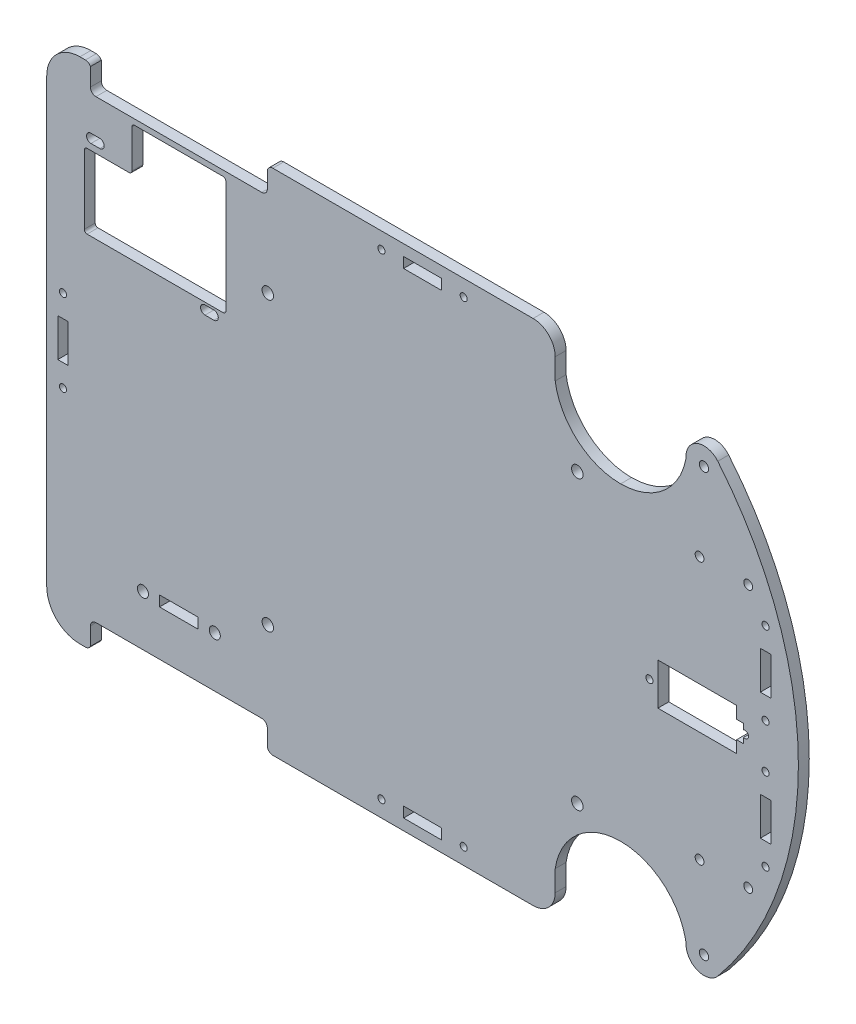
from build123d import *

# Parameters (mm, degrees)
CROQUIS1_W                  = 215.9
CROQUIS1_H                  = 146.05
SALIENTE_EXTRUIR1_DEPTH     = 3.1242
CROQUIS2_R                  = 1.3335
CORTAR_EXTRUIR1_DEPTH       = 131.36722652
CROQUIS9_R                  = 1.27
CORTAR_EXTRUIR6_DEPTH       = 131.36722652
CORTAR_EXTRUIR2_DEPTH       = 131.36722652
DIFERENCIAL_TRASERO_DEPTH   = 131.36722652
ENTRADA_TRANSMISION_DEPTH   = 131.36722652
CROQUIS10_R                 = 1.016
SERVO_DEPTH                 = 131.36722652
CROQUIS12_R                 = 1.651
SOPORTES_BS_DEPTH           = 131.36722652
CROQUIS7_W                  = 11.1125
CROQUIS7_H                  = 2.9972
CROQUIS7_R                  = 1.5875
SOPORTE_EJE_DEPTH           = 131.36722652
CROQUIS13_R                 = 1.016
CROQUIS13_W                 = 10.922
CROQUIS13_H                 = 2.9972
CROQUIS13_W_2               = 2.9972
CROQUIS13_H_2               = 10.922
SENSORES_DE_PRESENCIA_DEPTH = 131.36722652


with BuildPart() as part:
    # Croquis1 → Saliente-Extruir1 (new body)
    with BuildSketch(Plane.XY):
        Rectangle(CROQUIS1_W, CROQUIS1_H)
    extrude(amount=SALIENTE_EXTRUIR1_DEPTH)

    # Croquis2 → Cortar-Extruir1 (cut, through all)
    with BuildSketch(Plane.XY.offset(3.1242)):
        with Locations((80.8339125, 60.7314)):
            Circle(CROQUIS2_R)
        with Locations((80.8339125, -60.7314)):
            Circle(CROQUIS2_R)
    extrude(amount=-CORTAR_EXTRUIR1_DEPTH, mode=Mode.SUBTRACT)

    # Croquis9 → Cortar-Extruir6 (cut, through all)
    with BuildSketch(Plane.XY.offset(3.1242)):
        with Locations((93.5339125, 37.6809)):
            Circle(CROQUIS9_R)
        with Locations((93.5339125, -37.6809)):
            Circle(CROQUIS9_R)
        with Locations((79.5639125, 37.6809)):
            Circle(CROQUIS9_R)
        with Locations((79.5639125, -37.6809)):
            Circle(CROQUIS9_R)
    extrude(amount=-CORTAR_EXTRUIR6_DEPTH, mode=Mode.SUBTRACT)

    # Croquis3 → Cortar-Extruir2 (cut, through all)
    with BuildSketch(Plane.XY.offset(3.1242)):
        with BuildLine():
            ThreePointArc((31.75, 73.025), (36.240128061, 71.165128061), (38.1, 66.675))
            Line((38.1, 66.675), (38.1, 60.648925294))
            ThreePointArc((38.1, 60.648925294), (44.483976367, 49.058906773), (56.88726875, 44.45))
            ThreePointArc((56.88726875, 44.45), (68.952768587, 48.752886462), (75.572740263, 59.719521917))
            ThreePointArc((75.572740263, 59.719521917), (75.649024122, 60.222907145), (75.6745375, 60.7314))
            ThreePointArc((75.6745375, 60.7314), (79.079726884, 65.583408163), (84.800442563, 64.030762007))
            ThreePointArc((84.800442563, 64.030762007), (101.984927744, 34.043503392), (107.95, 0))
            Line((107.95, 0), (107.95, 73.025))
            Line((107.95, 73.025), (31.75, 73.025))
        make_face()
        with BuildLine():
            Line((107.95, -73.025), (107.95, 0))
            ThreePointArc((107.95, 0), (101.984927744, -34.043503392), (84.800442563, -64.030762007))
            ThreePointArc((84.800442563, -64.030762007), (79.079726884, -65.583408163), (75.6745375, -60.7314))
            ThreePointArc((75.6745375, -60.7314), (75.649024122, -60.222907145), (75.572740263, -59.719521917))
            ThreePointArc((75.572740263, -59.719521917), (68.952768587, -48.752886462), (56.88726875, -44.45))
            ThreePointArc((56.88726875, -44.45), (44.483976367, -49.058906773), (38.1, -60.648925294))
            Line((38.1, -60.648925294), (38.1, -66.675))
            ThreePointArc((38.1, -66.675), (36.240128061, -71.165128061), (31.75, -73.025))
            Line((31.75, -73.025), (107.95, -73.025))
        make_face()
        with BuildLine():
            ThreePointArc((-107.95, 63.5), (-105.160192091, 70.235192091), (-98.425, 73.025))
            Line((-98.425, 73.025), (-107.95, 73.025))
            Line((-107.95, 73.025), (-107.95, 63.5))
        make_face()
        with BuildLine():
            Line((-107.95, -73.025), (-98.425, -73.025))
            ThreePointArc((-98.425, -73.025), (-105.160192091, -70.235192091), (-107.95, -63.5))
            Line((-107.95, -63.5), (-107.95, -73.025))
        make_face()
    extrude(amount=-CORTAR_EXTRUIR2_DEPTH, mode=Mode.SUBTRACT)

    # Croquis8 → Diferencial trasero (cut, through all)
    with BuildSketch(Plane.XY.offset(3.1242)):
        with BuildLine():
            Line((-62.484, 29.2862), (-59.944, 29.2862))
            ThreePointArc((-59.944, 29.2862), (-58.674, 28.0162), (-59.944, 26.7462))
            Line((-59.944, 26.7462), (-62.484, 26.7462))
            ThreePointArc((-62.484, 26.7462), (-63.754, 28.0162), (-62.484, 29.2862))
        make_face()
        with BuildLine():
            Line((-95.25, 55.6006), (-92.71, 55.6006))
            ThreePointArc((-92.71, 55.6006), (-91.44, 54.3306), (-92.71, 53.0606))
            Line((-92.71, 53.0606), (-95.25, 53.0606))
            ThreePointArc((-95.25, 53.0606), (-96.52, 54.3306), (-95.25, 55.6006))
        make_face()
    extrude(amount=-DIFERENCIAL_TRASERO_DEPTH, mode=Mode.SUBTRACT)

    # Croquis11 → Entrada transmision (cut, through all)
    with BuildSketch(Plane.XY.offset(3.1242)):
        with BuildLine():
            Line((-95.398394794, 73.025), (-96.8375, 73.025))
            ThreePointArc((-96.8375, 73.025), (-95.984195865, 72.776166614), (-95.398394794, 72.107673453))
            Line((-95.398394794, 72.107673453), (-95.398394794, 67.0052))
            ThreePointArc((-95.398394794, 67.0052), (-94.93342681, 65.882667985), (-93.810894794, 65.4177))
            Line((-93.810894794, 65.4177), (-46.185894794, 65.4177))
            ThreePointArc((-46.185894794, 65.4177), (-45.063362779, 65.882667985), (-44.598394794, 67.0052))
            Line((-44.598394794, 67.0052), (-44.598394794, 71.4375))
            ThreePointArc((-44.598394794, 71.4375), (-44.13342681, 72.560032015), (-43.010894794, 73.025))
            Line((-43.010894794, 73.025), (-44.598394794, 73.025))
            Line((-44.598394794, 73.025), (-44.598394794, 80.6323))
            Line((-44.598394794, 80.6323), (-95.398394794, 80.6323))
            Line((-95.398394794, 80.6323), (-95.398394794, 73.025))
        make_face()
        with BuildLine():
            Line((-57.298394794, 63.8302), (-82.698394794, 63.8302))
            ThreePointArc((-82.698394794, 63.8302), (-83.259660802, 63.597716008), (-83.492144794, 63.03645))
            Line((-83.492144794, 63.03645), (-83.492144794, 52.0827))
            ThreePointArc((-83.492144794, 52.0827), (-83.724628787, 51.521433992), (-84.285894794, 51.28895))
            Line((-84.285894794, 51.28895), (-96.36125, 51.28895))
            ThreePointArc((-96.36125, 51.28895), (-96.922516008, 51.056466008), (-97.155, 50.4952))
            Line((-97.155, 50.4952), (-97.155, 30.7467))
            ThreePointArc((-97.155, 30.7467), (-96.922516008, 30.185433992), (-96.36125, 29.95295))
            Line((-96.36125, 29.95295), (-57.298394794, 29.95295))
            ThreePointArc((-57.298394794, 29.95295), (-56.737128787, 30.185433992), (-56.504644794, 30.7467))
            Line((-56.504644794, 30.7467), (-56.504644794, 63.03645))
            ThreePointArc((-56.504644794, 63.03645), (-56.737128787, 63.597716008), (-57.298394794, 63.8302))
        make_face()
        with BuildLine():
            Line((-95.398394794, -80.6323), (-44.598394794, -80.6323))
            Line((-44.598394794, -80.6323), (-44.598394794, -73.025))
            Line((-44.598394794, -73.025), (-43.010894794, -73.025))
            ThreePointArc((-43.010894794, -73.025), (-44.13342681, -72.560032015), (-44.598394794, -71.4375))
            Line((-44.598394794, -71.4375), (-44.598394794, -67.0052))
            ThreePointArc((-44.598394794, -67.0052), (-45.063362779, -65.882667985), (-46.185894794, -65.4177))
            Line((-46.185894794, -65.4177), (-93.810894794, -65.4177))
            ThreePointArc((-93.810894794, -65.4177), (-94.93342681, -65.882667985), (-95.398394794, -67.0052))
            Line((-95.398394794, -67.0052), (-95.398394794, -72.107673453))
            ThreePointArc((-95.398394794, -72.107673453), (-95.984195865, -72.776166614), (-96.8375, -73.025))
            Line((-96.8375, -73.025), (-95.398394794, -73.025))
            Line((-95.398394794, -73.025), (-95.398394794, -80.6323))
        make_face()
    extrude(amount=-ENTRADA_TRANSMISION_DEPTH, mode=Mode.SUBTRACT)

    # Croquis10 → Servo (cut, through all)
    with BuildSketch(Plane.XY.offset(3.1242)):
        with BuildLine():
            Line((67.5894, 5.9944), (67.5894, -5.9944))
            Line((67.5894, -5.9944), (90.1954, -5.9944))
            Line((90.1954, -5.9944), (90.1954, -2.54))
            Line((90.1954, -2.54), (92.2274, -2.54))
            Line((92.2274, -2.54), (92.2274, -0.936619619))
            ThreePointArc((92.2274, -0.936619619), (93.6371, 0), (92.2274, 0.936619619))
            Line((92.2274, 0.936619619), (92.2274, 2.54))
            Line((92.2274, 2.54), (90.1954, 2.54))
            Line((90.1954, 2.54), (90.1954, 5.9944))
            Line((90.1954, 5.9944), (67.5894, 5.9944))
        make_face()
        with Locations((65.1637, 0)):
            Circle(CROQUIS10_R)
    extrude(amount=-SERVO_DEPTH, mode=Mode.SUBTRACT)

    # Croquis12 → Soportes BS (cut, through all)
    with BuildSketch(Plane.XY.offset(3.1242)):
        with Locations((44.45, 41.275)):
            Circle(CROQUIS12_R)
        with Locations((-44.45, 41.275)):
            Circle(CROQUIS12_R)
        with Locations((-44.45, -41.275)):
            Circle(CROQUIS12_R)
        with Locations((44.45, -41.275)):
            Circle(CROQUIS12_R)
    extrude(amount=-SOPORTES_BS_DEPTH, mode=Mode.SUBTRACT)

    # Croquis7 → Soporte eje (cut, through all)
    with BuildSketch(Plane.XY.offset(3.1242)):
        with Locations((-69.998394794, -50.8889)):
            Rectangle(CROQUIS7_W, CROQUIS7_H)
        with Locations((-59.679644794, -50.8889)):
            Circle(CROQUIS7_R)
        with Locations((-80.317144794, -50.8889)):
            Circle(CROQUIS7_R)
    extrude(amount=-SOPORTE_EJE_DEPTH, mode=Mode.SUBTRACT)

    # Croquis13 → Sensores de presencia (cut, through all)
    with BuildSketch(Plane.XY.offset(3.1242)):
        with Locations((11.811, 68.3514)):
            Circle(CROQUIS13_R)
        with Locations((-103.2764, 11.811)):
            Circle(CROQUIS13_R)
        with Locations((-103.2764, -11.811)):
            Circle(CROQUIS13_R)
        with Locations((-11.811, 68.3514)):
            Circle(CROQUIS13_R)
        with Locations((-11.811, -68.3514)):
            Circle(CROQUIS13_R)
        with Locations((11.811, -68.3514)):
            Circle(CROQUIS13_R)
        with Locations((98.5139, 29.972)):
            Circle(CROQUIS13_R)
        with Locations((98.5139, 6.35)):
            Circle(CROQUIS13_R)
        with Locations((98.5139, -6.35)):
            Circle(CROQUIS13_R)
        with Locations((98.5139, -29.972)):
            Circle(CROQUIS13_R)
        with Locations((0, 68.3514)):
            Rectangle(CROQUIS13_W, CROQUIS13_H)
        with Locations((-103.2764, 0)):
            Rectangle(CROQUIS13_W_2, CROQUIS13_H_2)
        with Locations((0, -68.3514)):
            Rectangle(CROQUIS13_W, CROQUIS13_H)
        with Locations((98.5139, 18.161)):
            Rectangle(CROQUIS13_W_2, CROQUIS13_H_2)
        with Locations((98.5139, -18.161)):
            Rectangle(CROQUIS13_W_2, CROQUIS13_H_2)
    extrude(amount=-SENSORES_DE_PRESENCIA_DEPTH, mode=Mode.SUBTRACT)


solid = part.part
